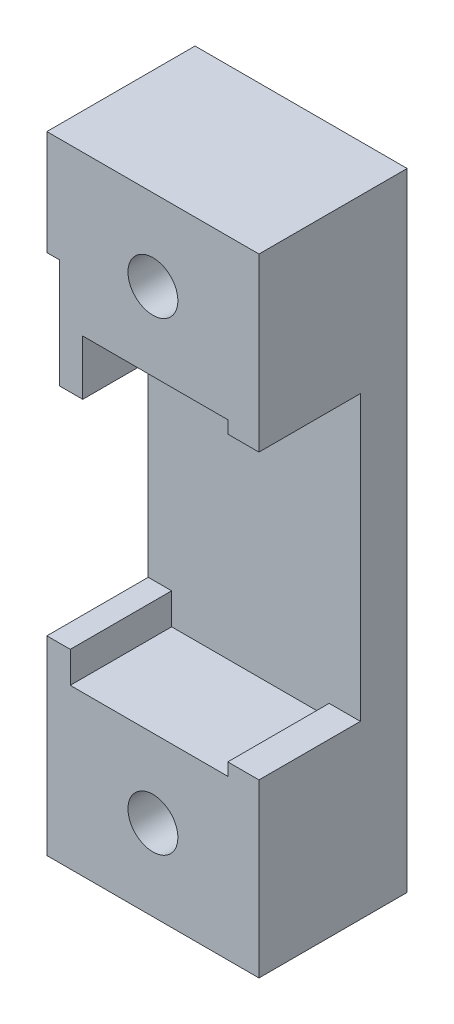
from build123d import *

# Parameters (mm, degrees)
SKETCH1_R               = 2.85
SKETCH1_R_2             = 1.6
BOSS_EXTRUDE1_DEPTH     = 6.5
SKETCH1_3_R             = 2.85
SKETCH1_3_R_2           = 1.6
BOSS_EXTRUDE2_DEPTH     = 3
CUT_EXTRUDE1_START      = -3
SKETCH1_4_R             = 2.85
CUT_EXTRUDE1_DEPTH      = 3.5
CUT_EXTRUDE1_DEPTH_BACK = 4


with BuildPart() as part:
    # Sketch1 → Boss-Extrude1 (new body)
    with BuildSketch(Plane(origin=(0, 0, 0), x_dir=(0, 1, 0), z_dir=(0, 0, 1))):
        Polygon((-7.9, 10.1), (-9.9, 10.1), (-9.9, 0), (-9.1, 0), (-9.1, -2), (-20.1, -2), (-20.1, 11.6), (-7.9, 11.6), align=None)
        with Locations((-14.9, 4.8)):
            Circle(SKETCH1_R, mode=Mode.SUBTRACT)
        Polygon((13.378898747, 11.6), (20.1, 11.6), (20.1, -2), (9.1, -2), (9.1, 0), (9.9, 0), (9.9, 9.3), (6.378898747, 9.3), (6.378898747, 10.8), (13.378898747, 10.8), align=None)
        with Locations((14.9, 4.8)):
            Circle(SKETCH1_R, mode=Mode.SUBTRACT)
        with Locations((-14.9, 4.8)):
            Circle(SKETCH1_R)
        with Locations((-14.9, 4.8)):
            Circle(SKETCH1_R_2, mode=Mode.SUBTRACT)
        with Locations((14.9, 4.8)):
            Circle(SKETCH1_R)
        with Locations((14.9, 4.8)):
            Circle(SKETCH1_R_2, mode=Mode.SUBTRACT)
    extrude(amount=BOSS_EXTRUDE1_DEPTH)

    # Sketch1_3 → Boss-Extrude2 (add)
    with BuildSketch(Plane(origin=(0, 0, 0), x_dir=(0, 1, 0), z_dir=(0, 0, 1))):
        with Locations((14.9, 4.8)):
            Circle(SKETCH1_3_R)
        with Locations((14.9, 4.8)):
            Circle(SKETCH1_3_R_2, mode=Mode.SUBTRACT)
        Polygon((13.378898747, 11.6), (20.1, 11.6), (20.1, -2), (9.1, -2), (9.1, 0), (9.9, 0), (9.9, 9.3), (6.378898747, 9.3), (6.378898747, 10.8), (13.378898747, 10.8), align=None)
        with Locations((14.9, 4.8)):
            Circle(SKETCH1_3_R, mode=Mode.SUBTRACT)
        Polygon((-7.9, 11.6), (13.378898747, 11.6), (13.378898747, 10.8), (6.378898747, 10.8), (6.378898747, 9.3), (9.9, 9.3), (9.9, 0), (9.1, 0), (9.1, -2), (-9.1, -2), (-9.1, 0), (-9.9, 0), (-9.9, 10.1), (-7.9, 10.1), align=None)
        with Locations((-14.9, 4.8)):
            Circle(SKETCH1_3_R)
        with Locations((-14.9, 4.8)):
            Circle(SKETCH1_3_R_2, mode=Mode.SUBTRACT)
        Polygon((-7.9, 10.1), (-9.9, 10.1), (-9.9, 0), (-9.1, 0), (-9.1, -2), (-20.1, -2), (-20.1, 11.6), (-7.9, 11.6), align=None)
        with Locations((-14.9, 4.8)):
            Circle(SKETCH1_3_R, mode=Mode.SUBTRACT)
    extrude(amount=-BOSS_EXTRUDE2_DEPTH)

    # Sketch1_4 → Cut-Extrude1 (cut, two sides)
    with BuildSketch(Plane(origin=(0, 0, 0), x_dir=(0, 1, 0), z_dir=(0, 0, 1)).offset(CUT_EXTRUDE1_START)) as cut_extrude1_sk:
        with Locations((14.9, 4.8)):
            Circle(SKETCH1_4_R)
        with Locations((-14.9, 4.8)):
            Circle(SKETCH1_4_R)
    extrude(amount=CUT_EXTRUDE1_DEPTH, mode=Mode.SUBTRACT)
    extrude(cut_extrude1_sk.sketch, amount=-CUT_EXTRUDE1_DEPTH_BACK, mode=Mode.SUBTRACT)


solid = part.part
